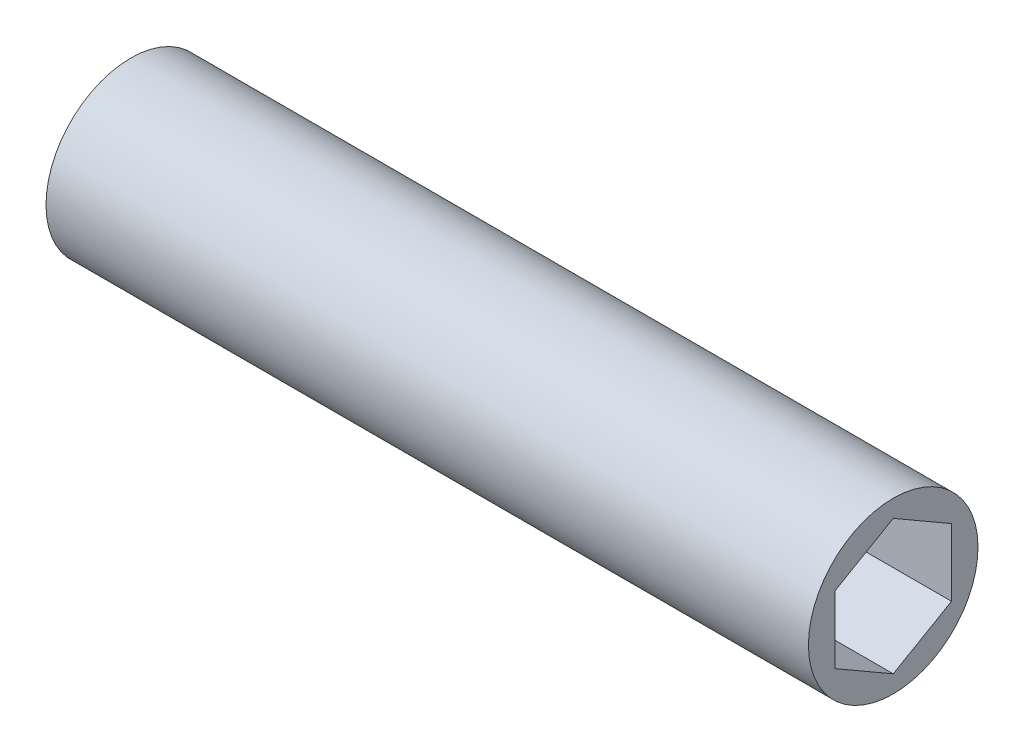
from build123d import *

# Parameters (mm, degrees)
SKETCH1_R           = 9.525
BOSS_EXTRUDE1_DEPTH = 85.6615


with BuildPart() as part:
    # Sketch1 → Boss-Extrude1 (new body)
    with BuildSketch(Plane(origin=(0, 0, 0), x_dir=(0, 0, -1), z_dir=(1, 0, 0))):
        Circle(SKETCH1_R)
        Polygon((0, 7.561484307), (-6.5484375, 3.780742153), (-6.5484375, -3.780742153), (0, -7.561484307), (6.5484375, -3.780742153), (6.5484375, 3.780742153), align=None, mode=Mode.SUBTRACT)
    extrude(amount=BOSS_EXTRUDE1_DEPTH)


solid = part.part
